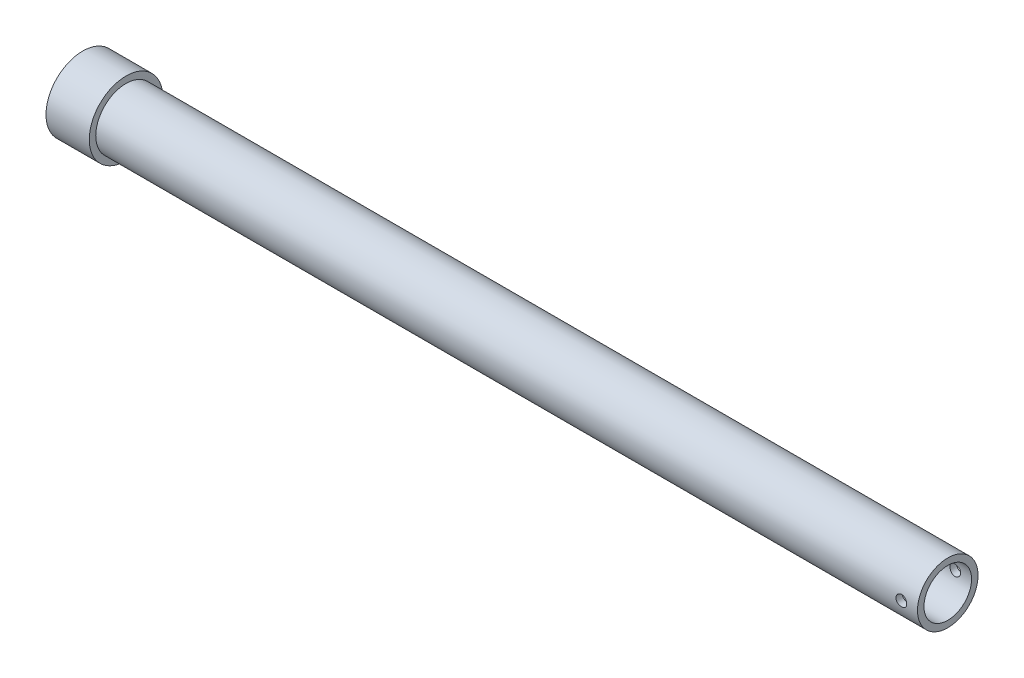
from build123d import *

# Parameters (mm, degrees)
SKETCH2_R               = 2.5
CUT_EXTRUDE1_DEPTH      = 18
CUT_EXTRUDE1_DEPTH_BACK = 18


with BuildPart() as part:
    # Sketch1 → Revolve1 (revolve)
    with BuildSketch(Plane.XY):
        Polygon((0, 0), (20, 0), (20, -11), (400, -11), (400, -14), (20, -14), (20, -17), (0, -17), align=None)
    revolve(axis=Axis((0, 0, 0), (1, 0, 0)))

    # Sketch2 → Cut-Extrude1 (cut, two sides)
    with BuildSketch(Plane.XY) as cut_extrude1_sk:
        with Locations((392.5, 0)):
            Circle(SKETCH2_R)
    extrude(amount=CUT_EXTRUDE1_DEPTH, mode=Mode.SUBTRACT)
    extrude(cut_extrude1_sk.sketch, amount=-CUT_EXTRUDE1_DEPTH_BACK, mode=Mode.SUBTRACT)


solid = part.part
